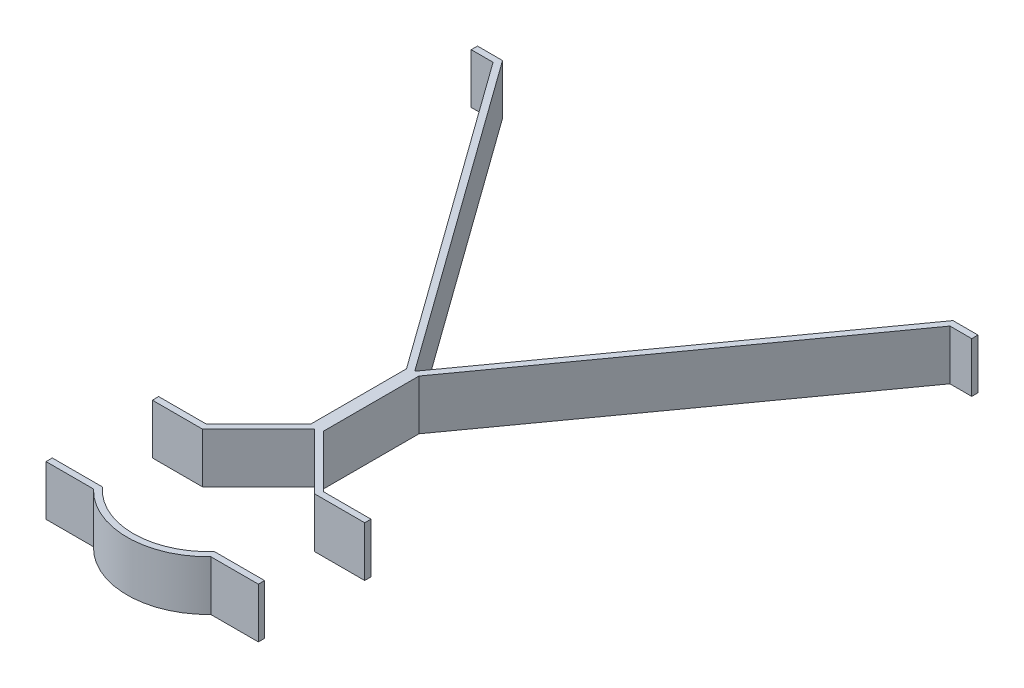
from build123d import *

# Parameters (mm, degrees)
BOSS_EXTRUDE1_DEPTH   = 12.7
BOSS_EXTRUDE1_2_DEPTH = 12.7


with BuildPart() as part:
    # Sketch1 → Boss-Extrude1 (new body, symmetric)
    with BuildSketch(Plane(origin=(0, 0, 0), x_dir=(1, 0, 0), z_dir=(0, 1, 0))):
        Polygon((-127, 184.243463274), (-114.3, 184.243463274), (0, 25.4), (114.3, 184.243463274), (127, 184.243463274), (127, 181.068463274), (115.926901433, 181.068463274), (3.175, 24.376402781), (3.175, -24.084871939), (29.796664787, -50.706536726), (53.881536726, -50.706536726), (53.881536726, -53.881536726), (28.481536726, -53.881536726), (0, -25.4), (-28.481536726, -53.881536726), (-53.881536726, -53.881536726), (-53.881536726, -50.706536726), (-29.796664787, -50.706536726), (-3.175, -24.084871939), (-3.175, 24.376402781), (-115.926901433, 181.068463274), (-127, 181.068463274), align=None)
    extrude(amount=BOSS_EXTRUDE1_DEPTH, both=True)


with BuildPart() as body_2:
    # Sketch1 → Boss-Extrude1 2 (new body, symmetric)
    with BuildSketch(Plane(origin=(0, 0, 0), x_dir=(1, 0, 0), z_dir=(0, 1, 0))):
        with BuildLine():
            Line((-53.881536726, -104.681536726), (-28.398063314, -104.681536726))
            ThreePointArc((-28.398063314, -104.681536726), (0, -117.381536726), (28.398063314, -104.681536726))
            Line((28.398063314, -104.681536726), (53.881536726, -104.681536726))
            Line((53.881536726, -104.681536726), (53.881536726, -107.856536726))
            Line((53.881536726, -107.856536726), (29.784140075, -107.856536726))
            ThreePointArc((29.784140075, -107.856536726), (0, -120.556536726), (-29.784140075, -107.856536726))
            Line((-29.784140075, -107.856536726), (-53.881536726, -107.856536726))
            Line((-53.881536726, -107.856536726), (-53.881536726, -104.681536726))
        make_face()
    extrude(amount=BOSS_EXTRUDE1_2_DEPTH, both=True)


solid = Compound([part.part, body_2.part])
